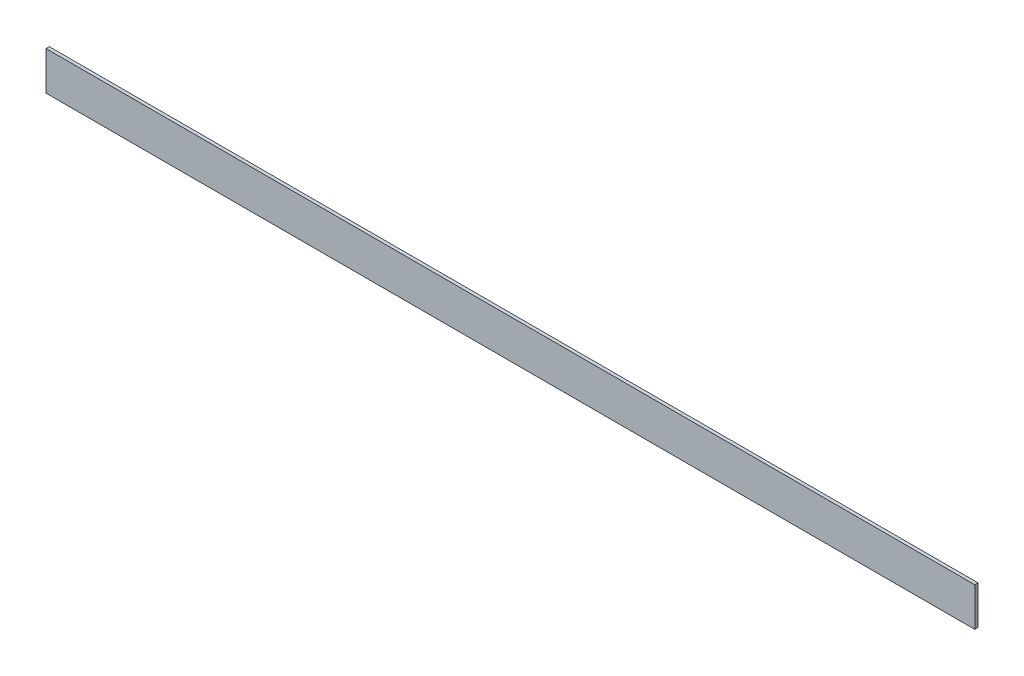
from build123d import *

# Parameters (mm, degrees)
SKETCH1_W           = 6.35
SKETCH1_H           = 76.2
BOSS_EXTRUDE1_DEPTH = 1828.8


with BuildPart() as part:
    # Sketch1 → Boss-Extrude1 (new body)
    with BuildSketch(Plane(origin=(0, 0, 0), x_dir=(0, 0, -1), z_dir=(1, 0, 0))):
        Rectangle(SKETCH1_W, SKETCH1_H)
    extrude(amount=BOSS_EXTRUDE1_DEPTH)


solid = part.part
